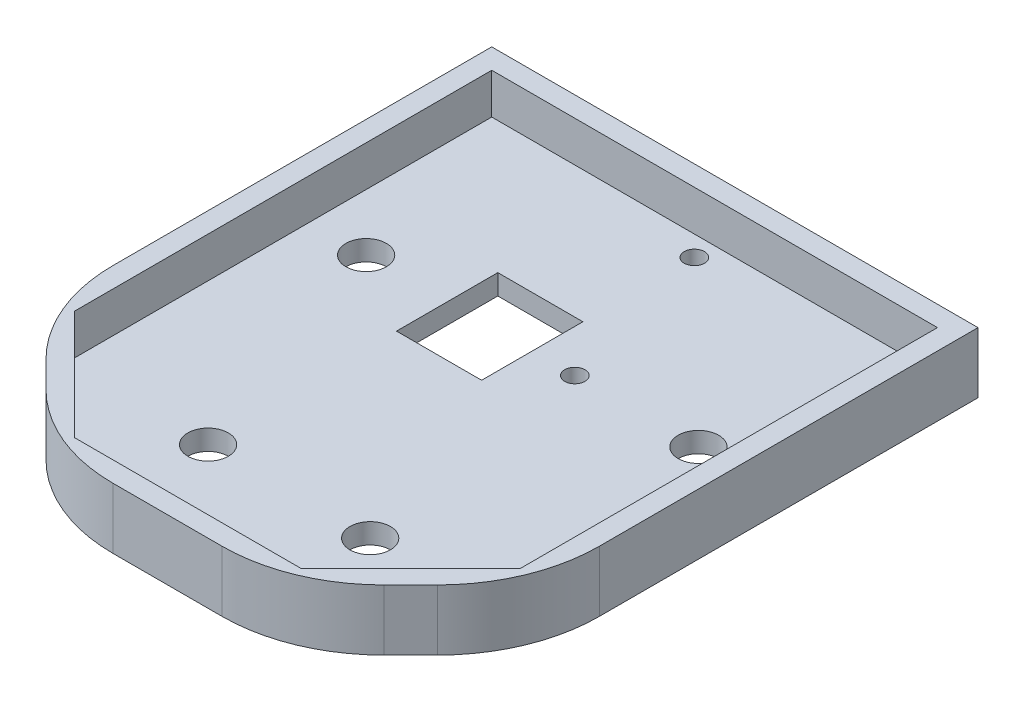
from build123d import *

# Parameters (mm, degrees)
SKETCH1_R           = 6.35
SKETCH1_R_2         = 3.175
SKETCH1_W           = 26.67
SKETCH1_H           = 31.75
BOSS_EXTRUDE1_DEPTH = 6.35
BOSS_EXTRUDE2_DEPTH = 19.05
FILLET1_R           = 50.8


with BuildPart() as part:
    # Sketch1 → Boss-Extrude1 (new body)
    with BuildSketch(Plane(origin=(0, 0, 0), x_dir=(1, 0, 0), z_dir=(0, 1, 0))):
        Polygon((-76.2, 88.9), (76.2, 88.9), (76.2, -50.8), (38.1, -88.9), (-38.1, -88.9), (-76.2, -50.8), align=None)
        with Locations((52.07, 25.4)):
            Circle(SKETCH1_R, mode=Mode.SUBTRACT)
        with Locations((-25.4, -50.8)):
            Circle(SKETCH1_R, mode=Mode.SUBTRACT)
        with Locations((25.4, -50.8)):
            Circle(SKETCH1_R, mode=Mode.SUBTRACT)
        with Locations((0, -76.2)):
            Circle(SKETCH1_R_2, mode=Mode.SUBTRACT)
        with Locations((0, 76.2)):
            Circle(SKETCH1_R_2, mode=Mode.SUBTRACT)
        with Locations((-52.07, 25.4)):
            Circle(SKETCH1_R, mode=Mode.SUBTRACT)
        with Locations((13.335, 25.4)):
            Circle(SKETCH1_R_2, mode=Mode.SUBTRACT)
        with Locations((-13.335, 25.4)):
            Rectangle(SKETCH1_W, SKETCH1_H, mode=Mode.SUBTRACT)
    extrude(amount=BOSS_EXTRUDE1_DEPTH)

    # Sketch2 → Boss-Extrude2 (add)
    with BuildSketch(Plane(origin=(0, 0, 0), x_dir=(1, 0, 0), z_dir=(0, 1, 0))):
        Polygon((-76.2, 88.9), (-76.2, -50.8), (-38.1, -88.9), (38.1, -88.9), (76.2, -50.8), (76.2, 88.9), align=None)
        Polygon((-69.85, 82.55), (-69.85, -48.169743879), (-35.469743879, -82.55), (35.469743879, -82.55), (69.85, -48.169743879), (69.85, 82.55), align=None, mode=Mode.SUBTRACT)
    extrude(amount=BOSS_EXTRUDE2_DEPTH)

    # Fillet1
    fillet1_edges = [part.edges().sort_by_distance(p)[0] for p in [
        (76.2, 9.525, 50.8),
        (38.1, 9.525, 88.9),
        (-38.1, 9.525, 88.9),
        (-76.2, 9.525, 50.8),
    ]]
    fillet(fillet1_edges, radius=FILLET1_R)


solid = part.part
